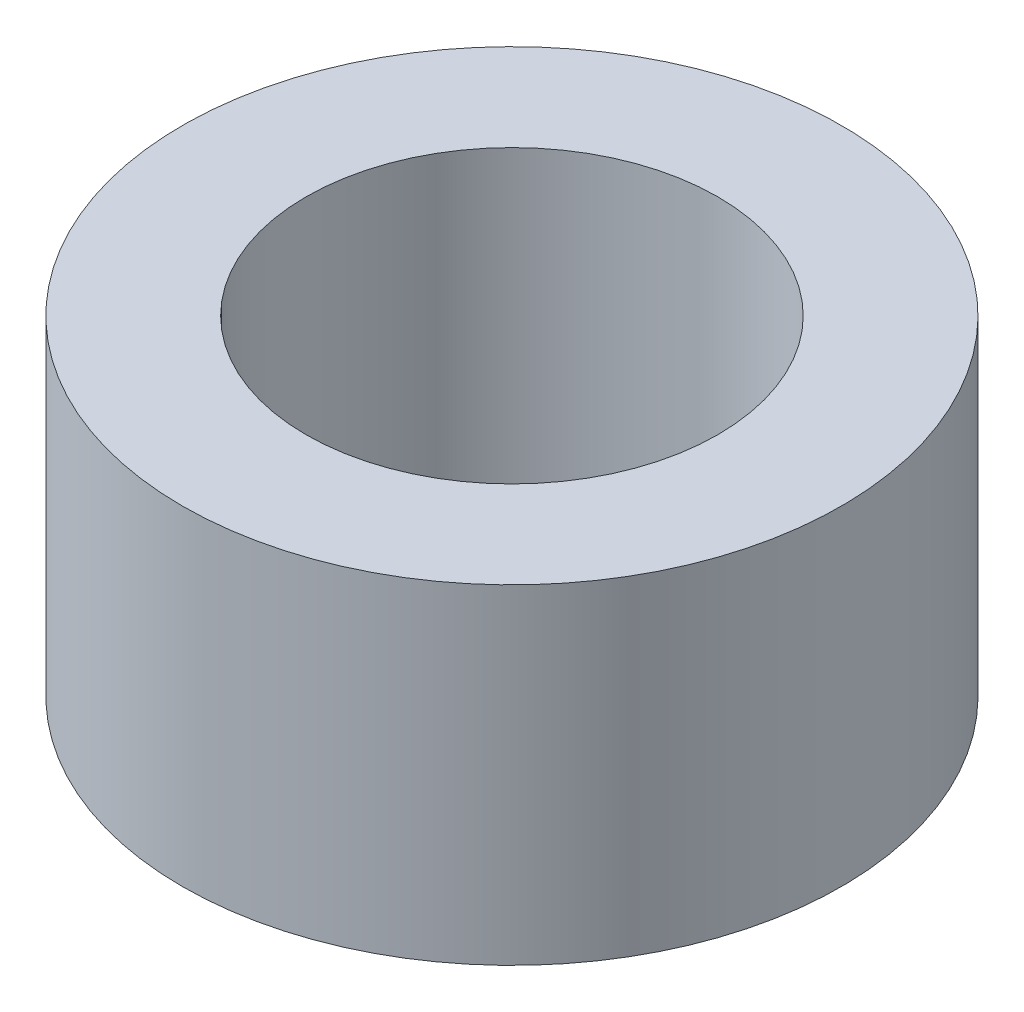
from build123d import *

# Parameters (mm, degrees)
SKETCH1_R           = 5
SKETCH1_R_2         = 3.125
BOSS_EXTRUDE1_DEPTH = 2.5


with BuildPart() as part:
    # Sketch1 → Boss-Extrude1 (new body, symmetric)
    with BuildSketch(Plane(origin=(0, 0, 0), x_dir=(1, 0, 0), z_dir=(0, 1, 0))):
        Circle(SKETCH1_R)
        Circle(SKETCH1_R_2, mode=Mode.SUBTRACT)
    extrude(amount=BOSS_EXTRUDE1_DEPTH, both=True)


solid = part.part
